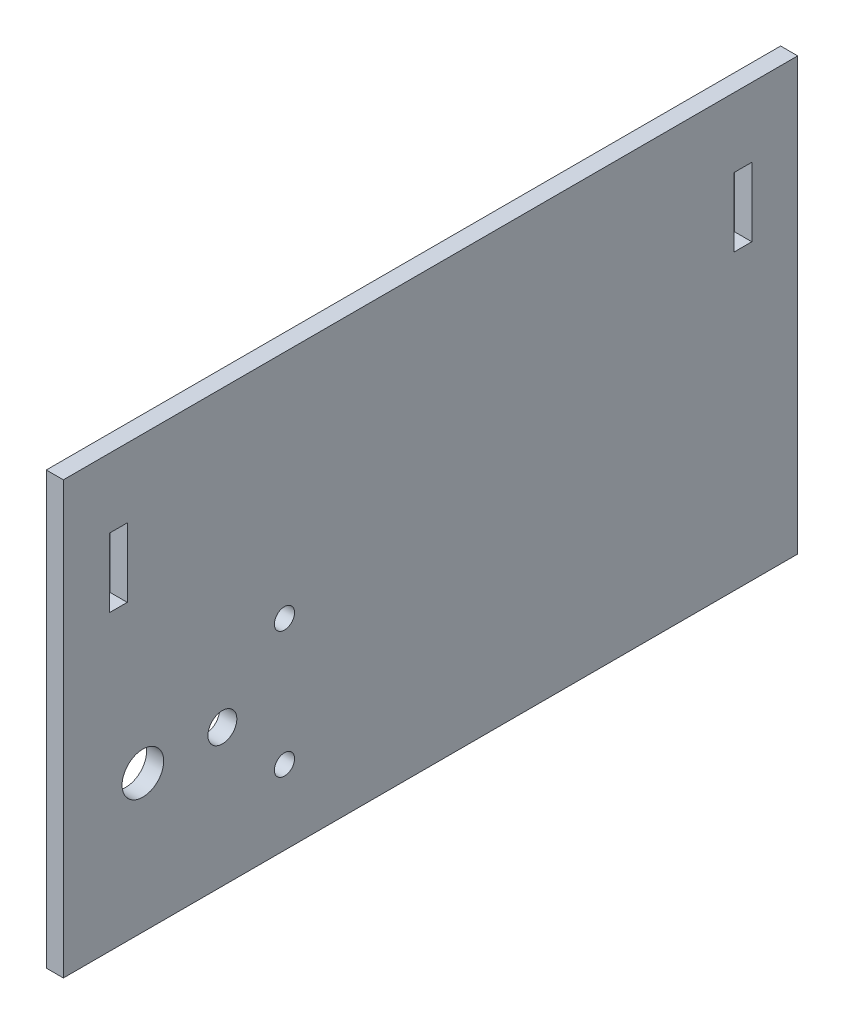
from build123d import *

# Parameters (mm, degrees)
SKETCH1_W           = 101.6
SKETCH1_H           = 59.69
BOSS_EXTRUDE1_DEPTH = 2.3622
CUT_EXTRUDE1_REACH  = 4.362
SKETCH2_R           = 1.4
SKETCH2_R_2         = 2
SKETCH2_R_3         = 2.876999961
SKETCH4_W           = 2.4892
SKETCH4_H           = 9.525
CUT_EXTRUDE3_DEPTH  = 3.3622


with BuildPart() as part:
    # Sketch1 → Boss-Extrude1 (new body)
    with BuildSketch(Plane(origin=(0, 0, 0), x_dir=(0, 0, -1), z_dir=(1, 0, 0))):
        with Locations((50.8, 29.845)):
            Rectangle(SKETCH1_W, SKETCH1_H)
    extrude(amount=BOSS_EXTRUDE1_DEPTH)

    # Sketch2 → Cut-Extrude1 (cut, up to next)
    with BuildSketch(Plane(origin=(2.3622, 0, 0), x_dir=(0, 0, -1), z_dir=(1, 0, 0)), mode=Mode.PRIVATE) as cut_extrude1_sk1:
        with Locations((30.59102, 10.3)):
            Circle(SKETCH2_R)
    cut_extrude1_tool1 = extrude(cut_extrude1_sk1.sketch, amount=-CUT_EXTRUDE1_REACH, mode=Mode.PRIVATE) & part.part
    add(cut_extrude1_tool1.solids().sort_by_distance((2.3622, 10.3, -30.59102))[0], mode=Mode.SUBTRACT)
    # Sketch2 → Cut-Extrude1 (cut, up to next)
    with BuildSketch(Plane(origin=(2.3622, 0, 0), x_dir=(0, 0, -1), z_dir=(1, 0, 0)), mode=Mode.PRIVATE) as cut_extrude1_sk2:
        with Locations((30.59102, 27.8)):
            Circle(SKETCH2_R)
    cut_extrude1_tool2 = extrude(cut_extrude1_sk2.sketch, amount=-CUT_EXTRUDE1_REACH, mode=Mode.PRIVATE) & part.part
    add(cut_extrude1_tool2.solids().sort_by_distance((2.3622, 27.8, -30.59102))[0], mode=Mode.SUBTRACT)
    # Sketch2 → Cut-Extrude1 (cut, up to next)
    with BuildSketch(Plane(origin=(2.3622, 0, 0), x_dir=(0, 0, -1), z_dir=(1, 0, 0)), mode=Mode.PRIVATE) as cut_extrude1_sk3:
        with Locations((22.0000034, 19.05)):
            Circle(SKETCH2_R_2)
    cut_extrude1_tool3 = extrude(cut_extrude1_sk3.sketch, amount=-CUT_EXTRUDE1_REACH, mode=Mode.PRIVATE) & part.part
    add(cut_extrude1_tool3.solids().sort_by_distance((2.3622, 19.05, -22.000003))[0], mode=Mode.SUBTRACT)
    # Sketch2 → Cut-Extrude1 (cut, up to next)
    with BuildSketch(Plane(origin=(2.3622, 0, 0), x_dir=(0, 0, -1), z_dir=(1, 0, 0)), mode=Mode.PRIVATE) as cut_extrude1_sk4:
        with Locations((11, 19.05)):
            Circle(SKETCH2_R_3)
    cut_extrude1_tool4 = extrude(cut_extrude1_sk4.sketch, amount=-CUT_EXTRUDE1_REACH, mode=Mode.PRIVATE) & part.part
    add(cut_extrude1_tool4.solids().sort_by_distance((2.3622, 19.05, -11))[0], mode=Mode.SUBTRACT)

    # Sketch4 → Cut-Extrude3 (cut, through all)
    with BuildSketch(Plane(origin=(2.3622, 0, 0), x_dir=(0, 0, -1), z_dir=(1, 0, 0))):
        with Locations((7.5946, 45.3517)):
            Rectangle(SKETCH4_W, SKETCH4_H)
        with Locations((94.0054, 45.3517)):
            Rectangle(SKETCH4_W, SKETCH4_H)
    extrude(amount=-CUT_EXTRUDE3_DEPTH, mode=Mode.SUBTRACT)


solid = part.part
